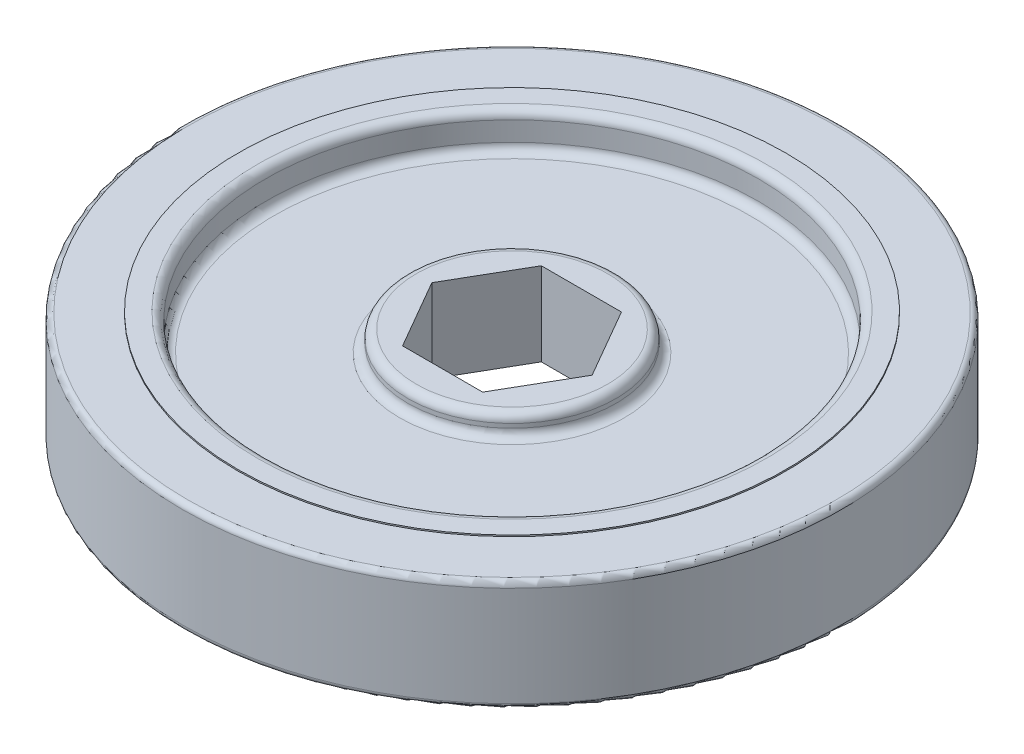
from build123d import *

# Parameters (mm, degrees)
SKETCH1_R           = 30.1625
SKETCH1_R_2         = 25.0825
BOSS_EXTRUDE1_DEPTH = 5.08
SKETCH1_3_R         = 25.0825
SKETCH1_3_R_2       = 22.5425
BOSS_EXTRUDE2_DEPTH = 5.207
SKETCH1_4_R         = 9.525
BOSS_EXTRUDE3_DEPTH = 3.81
SKETCH1_5_R         = 22.5425
SKETCH1_5_R_2       = 9.525
BOSS_EXTRUDE4_DEPTH = 1.905
FILLET1_R           = 0.762
FILLET2_R           = 0.508


with BuildPart() as part:
    # Sketch1 → Boss-Extrude1 (new, symmetric)
    with BuildSketch(Plane(origin=(0, 0, 0), x_dir=(1, 0, 0), z_dir=(0, 1, 0))):
        Circle(SKETCH1_R)
        Circle(SKETCH1_R_2, mode=Mode.SUBTRACT)
    extrude(amount=BOSS_EXTRUDE1_DEPTH, both=True)

    # Sketch1_3 → Boss-Extrude2 (add, symmetric)
    with BuildSketch(Plane(origin=(0, 0, 0), x_dir=(1, 0, 0), z_dir=(0, 1, 0))):
        Circle(SKETCH1_3_R)
        Circle(SKETCH1_3_R_2, mode=Mode.SUBTRACT)
    extrude(amount=BOSS_EXTRUDE2_DEPTH, both=True)



with BuildPart() as body_2:
    # Sketch1_4 → Boss-Extrude3 (new, symmetric)
    with BuildSketch(Plane(origin=(0, 0, 0), x_dir=(1, 0, 0), z_dir=(0, 1, 0))):
        Circle(SKETCH1_4_R)
        Polygon((-3.666174209, 6.35), (3.666174209, 6.35), (7.332348419, 0), (3.666174209, -6.35), (-3.666174209, -6.35), (-7.332348419, 0), align=None, mode=Mode.SUBTRACT)
    extrude(amount=BOSS_EXTRUDE3_DEPTH, both=True)


with BuildPart() as part_1:
    add(part.part)

    add(body_2.part)  # Boss-Extrude4 merges body 2
    # Sketch1_5 → Boss-Extrude4 (add, symmetric)
    with BuildSketch(Plane(origin=(0, 0, 0), x_dir=(1, 0, 0), z_dir=(0, 1, 0))):
        Circle(SKETCH1_5_R)
        Circle(SKETCH1_5_R_2, mode=Mode.SUBTRACT)
    extrude(amount=BOSS_EXTRUDE4_DEPTH, both=True)

    # Fillet1
    fillet1_edges = [part_1.edges().sort_by_distance(p)[0] for p in [
        (-22.5425, -1.905, 0),
        (-22.5425, 5.207, 0),
        (-22.5425, 1.905, 0),
        (-9.525, 3.81, 0),
        (-9.525, 1.905, 0),
        (-22.5425, -5.207, 0),
        (-9.525, -3.81, 0),
        (-9.525, -1.905, 0),
    ]]
    fillet(fillet1_edges, radius=FILLET1_R)

    # Fillet2
    fillet2_edges = [part_1.edges().sort_by_distance(p)[0] for p in [
        (-30.1625, -5.08, 0),
        (-30.1625, 5.08, 0),
    ]]
    fillet(fillet2_edges, radius=FILLET2_R)


solid = part_1.part
